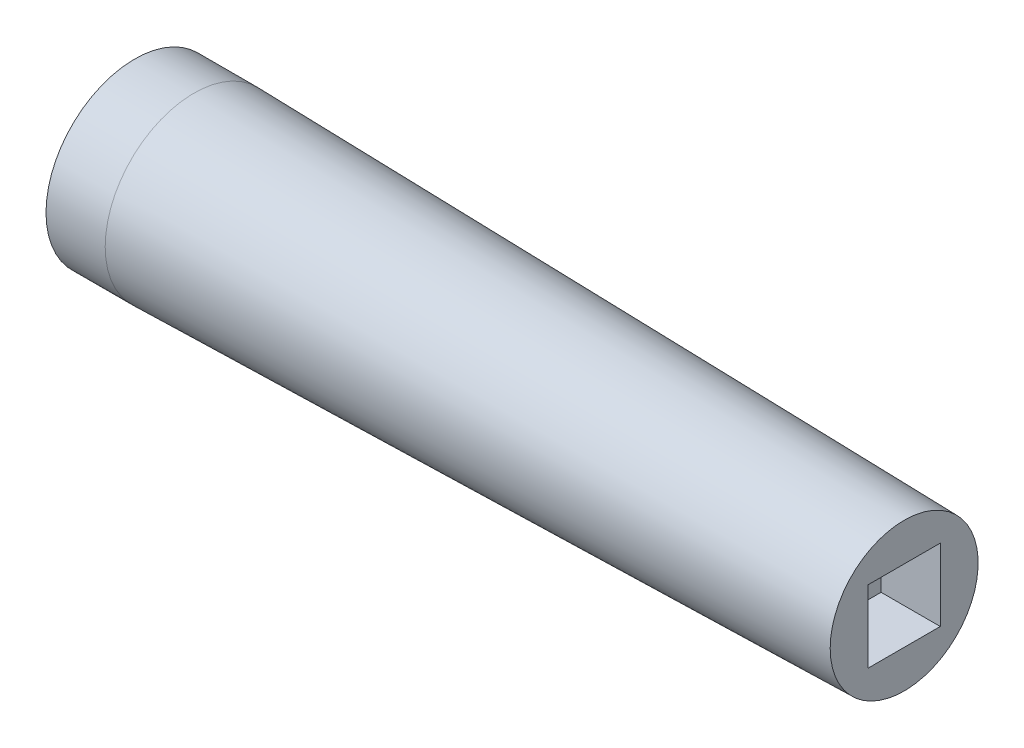
from build123d import *

# Parameters (mm, degrees)
SKETCH3_W          = 15.494
SKETCH3_H          = 15.494
CUT_EXTRUDE1_DEPTH = 12.7


with BuildPart() as part:
    # Sketch2 → Revolve5 (revolve)
    with BuildSketch(Plane.XY):
        Polygon((0, 0), (0, 19.05), (12.7, 19.05), (165.1, 15.875), (165.1, 0), align=None)
    revolve(axis=Axis((-5.73790049, 0, 0), (1, 0, 0)))

    # Sketch3 → Cut-Extrude1 (cut)
    with BuildSketch(Plane(origin=(165.1, 0, 0), x_dir=(0, 0, -1), z_dir=(1, 0, 0))):
        Rectangle(SKETCH3_W, SKETCH3_H)
    extrude(amount=-CUT_EXTRUDE1_DEPTH, mode=Mode.SUBTRACT)


solid = part.part
